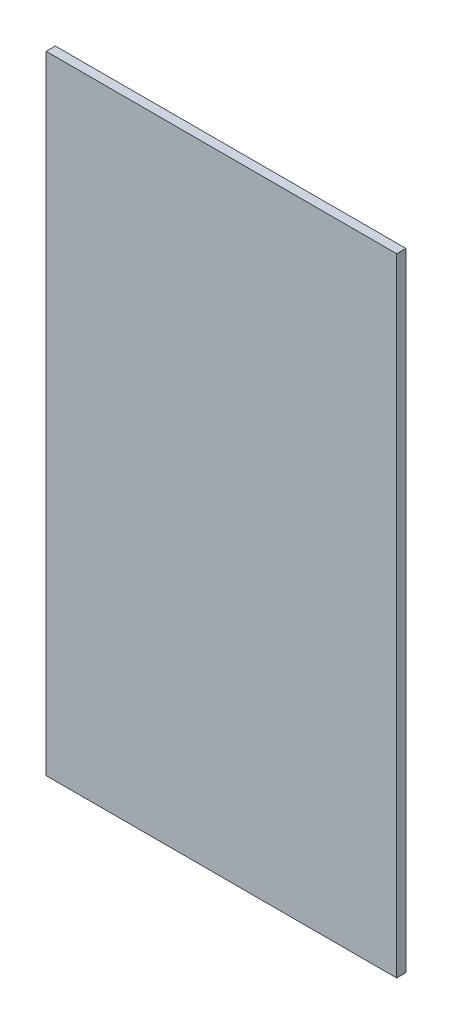
from build123d import *

# Parameters (mm, degrees)
ESQUISSE1_W        = 380
ESQUISSE1_H        = 680
BOSS_EXTRU_1_DEPTH = 10


with BuildPart() as part:
    # Esquisse1 → Boss.-Extru.1 (new body)
    with BuildSketch(Plane.XY):
        Rectangle(ESQUISSE1_W, ESQUISSE1_H)
    extrude(amount=BOSS_EXTRU_1_DEPTH)


solid = part.part
